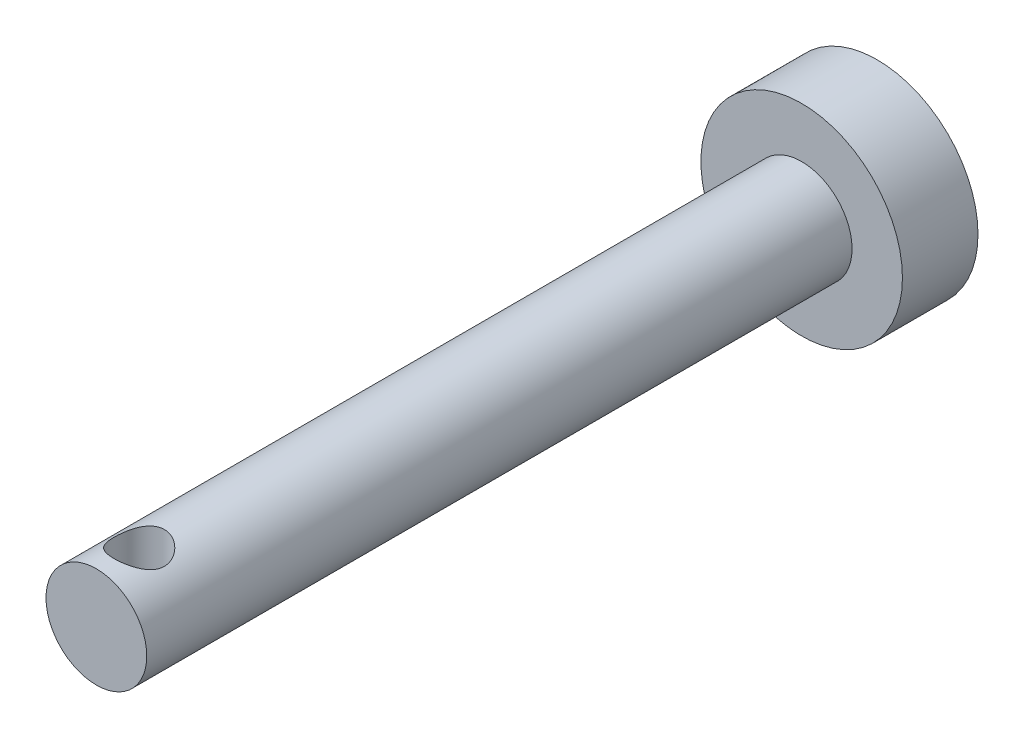
from build123d import *

# Parameters (mm, degrees)
SKETCH3_W               = 300
SKETCH3_H               = 7.83336639
CUT_EXTRUDE1_DEPTH      = 5
CUT_EXTRUDE1_DEPTH_BACK = 5
SKETCH4_R               = 1
CUT_EXTRUDE2_DEPTH      = 5
CUT_EXTRUDE2_DEPTH_BACK = 5


with BuildPart() as part:
    # Sketch2 → Revolve1 (revolve)
    with BuildSketch(Plane(origin=(0, 0, 0), x_dir=(0, 0, -1), z_dir=(1, 0, 0))):
        Polygon((125, 0), (125, 4), (122, 4), (122, 2), (-125, 2), (-125, 0), align=None)
    revolve(axis=Axis((0, 0, 125), (0, 0, -1)))

    # Sketch3 → Cut-Extrude1 (cut, two sides)
    with BuildSketch(Plane(origin=(0, 0, 0), x_dir=(0, 0, -1), z_dir=(1, 0, 0))) as cut_extrude1_sk:
        with Locations((-56, 0.150641661)):
            Rectangle(SKETCH3_W, SKETCH3_H)
    extrude(amount=CUT_EXTRUDE1_DEPTH, mode=Mode.SUBTRACT)
    extrude(cut_extrude1_sk.sketch, amount=-CUT_EXTRUDE1_DEPTH_BACK, mode=Mode.SUBTRACT)

    # Sketch4 → Cut-Extrude2 (cut, two sides)
    with BuildSketch(Plane(origin=(0, 0, 0), x_dir=(1, 0, 0), z_dir=(0, 1, 0))) as cut_extrude2_sk:
        with Locations((0, 95.7)):
            Circle(SKETCH4_R)
    extrude(amount=CUT_EXTRUDE2_DEPTH, mode=Mode.SUBTRACT)
    extrude(cut_extrude2_sk.sketch, amount=-CUT_EXTRUDE2_DEPTH_BACK, mode=Mode.SUBTRACT)


solid = part.part
